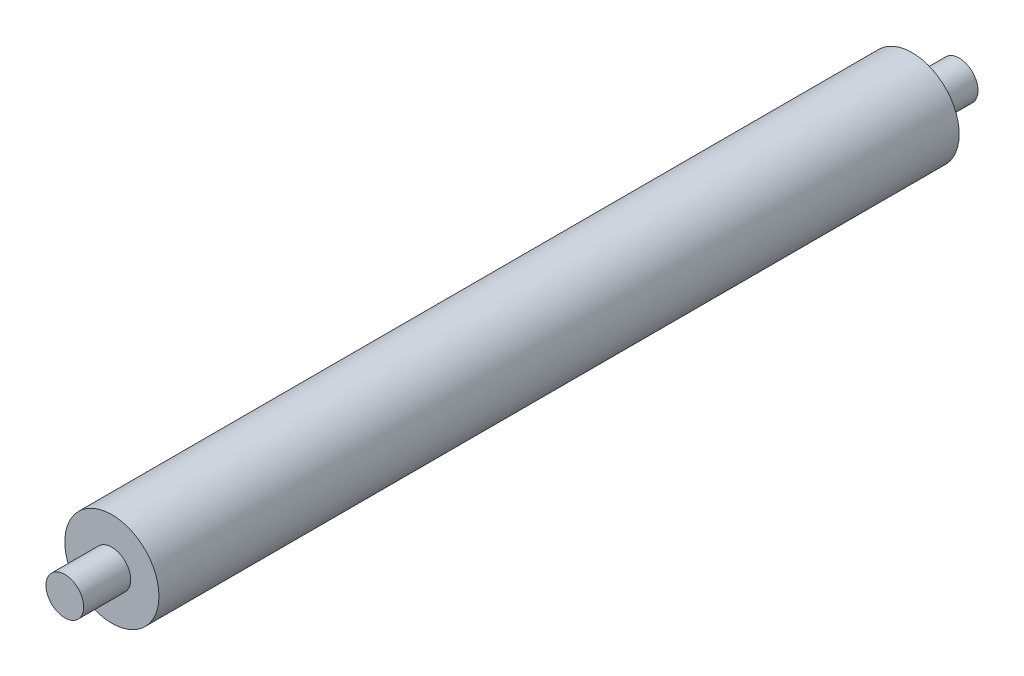
from build123d import *


with BuildPart() as part:
    # Sketch2 → Revolve1 (revolve)
    with BuildSketch(Plane(origin=(0, 0, 0), x_dir=(0, 0, -1), z_dir=(1, 0, 0))):
        Polygon((-47.5, 0), (47.5, 0), (47.5, 2), (42.5, 2), (42.5, 5), (-42.5, 5), (-42.5, 2), (-47.5, 2), align=None)
    revolve(axis=Axis((0, 0, 47.5), (0, 0, -1)))


solid = part.part
